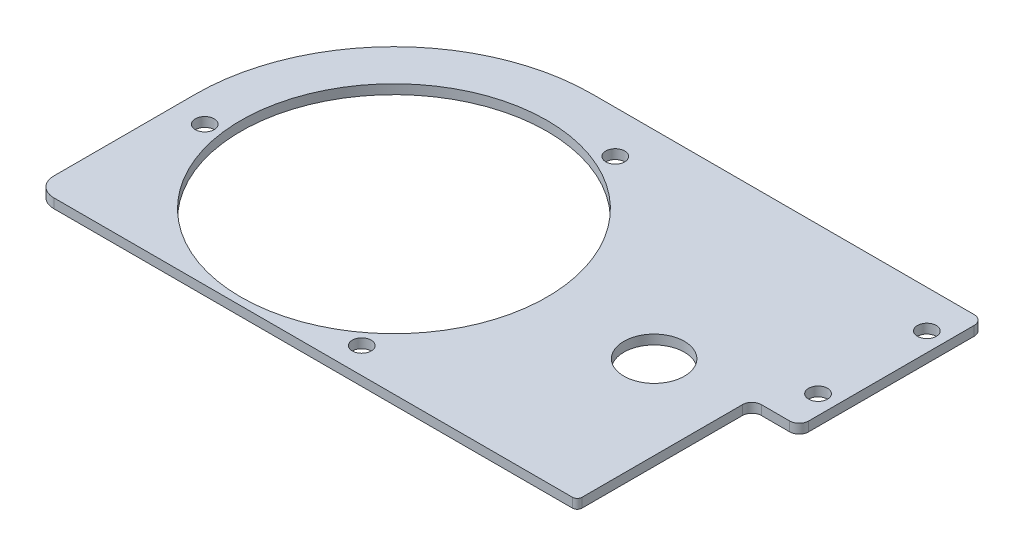
from build123d import *

# Parameters (mm, degrees)
SKETCH1_R           = 102.87
SKETCH1_R_2         = 6.35
BOSS_EXTRUDE1_DEPTH = 6.35
SKETCH6_R           = 20.32
CUT_EXTRUDE1_DEPTH  = 28.448


with BuildPart() as part:
    # Sketch1 → Boss-Extrude1 (new body)
    with BuildSketch(Plane(origin=(0, 0, 0), x_dir=(1, 0, 0), z_dir=(0, 1, 0))):
        with BuildLine():
            Line((256.521079071, 133.368920929), (0, 133.368920929))
            ThreePointArc((0, 133.368920929), (-94.306068389, 94.306068389), (-133.368920929, 0))
            Line((-133.368920929, 0), (-133.368920929, -95.231079071))
            ThreePointArc((-133.368920929, -95.231079071), (-129.64917705, -104.211335192), (-120.668920929, -107.931079071))
            Line((-120.668920929, -107.931079071), (227.955539535, -107.931079071))
            ThreePointArc((227.955539535, -107.931079071), (230.193914007, -107.003914007), (231.121079071, -104.765539535))
            Line((231.121079071, -104.765539535), (231.121079071, 3.100777109))
            ThreePointArc((231.121079071, 3.100777109), (232.98095101, 7.59090517), (237.471079071, 9.450777109))
            Line((237.471079071, 9.450777109), (256.521079071, 9.450777109))
            ThreePointArc((256.521079071, 9.450777109), (261.011207131, 11.310649048), (262.871079071, 15.800777109))
            Line((262.871079071, 15.800777109), (262.871079071, 127.018920929))
            ThreePointArc((262.871079071, 127.018920929), (261.011207131, 131.50904899), (256.521079071, 133.368920929))
        make_face()
        Circle(SKETCH1_R, mode=Mode.SUBTRACT)
        with Locations((-112.738641363, -14.374963544)):
            Circle(SKETCH1_R_2, mode=Mode.SUBTRACT)
        with Locations((43.920237074, 104.822009181)):
            Circle(SKETCH1_R_2, mode=Mode.SUBTRACT)
        with Locations((68.818404289, -90.447045637)):
            Circle(SKETCH1_R_2, mode=Mode.SUBTRACT)
        with Locations((250.171079071, 107.968920929)):
            Circle(SKETCH1_R_2, mode=Mode.SUBTRACT)
        with Locations((250.171079071, 34.850777109)):
            Circle(SKETCH1_R_2, mode=Mode.SUBTRACT)
    extrude(amount=BOSS_EXTRUDE1_DEPTH)

    # Sketch6 → Cut-Extrude1 (cut)
    with BuildSketch(Plane(origin=(0, 0, 0), x_dir=(1, 0, 0), z_dir=(0, 1, 0))):
        with Locations((174.732998702, 0.124686489)):
            Circle(SKETCH6_R)
    extrude(amount=CUT_EXTRUDE1_DEPTH, mode=Mode.SUBTRACT)


solid = part.part
